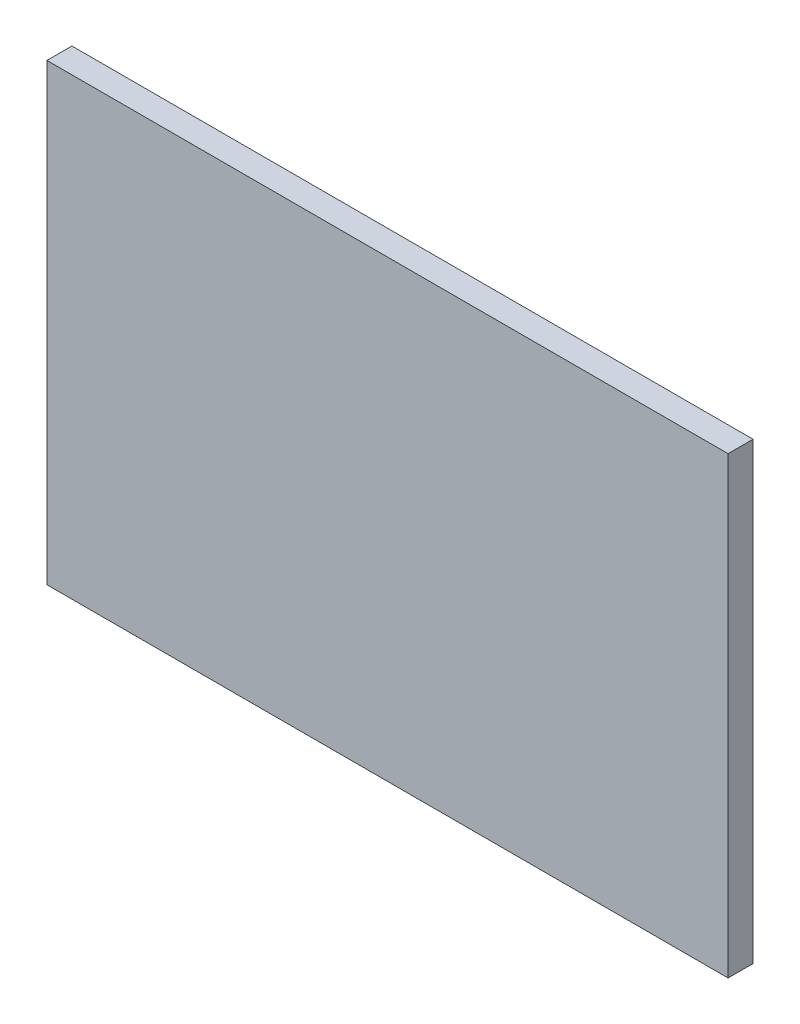
from build123d import *

# Parameters (mm, degrees)
SKETCH_1_W      = 30
SKETCH_1_H      = 20
EXTRUDE_1_DEPTH = 1.1


with BuildPart() as part:
    # 草图1 → 凸台-拉伸1 (new body)
    with BuildSketch(Plane.XY):
        with Locations((3.248713214, 2.309367287)):
            Rectangle(SKETCH_1_W, SKETCH_1_H)
    extrude(amount=EXTRUDE_1_DEPTH)


solid = part.part
